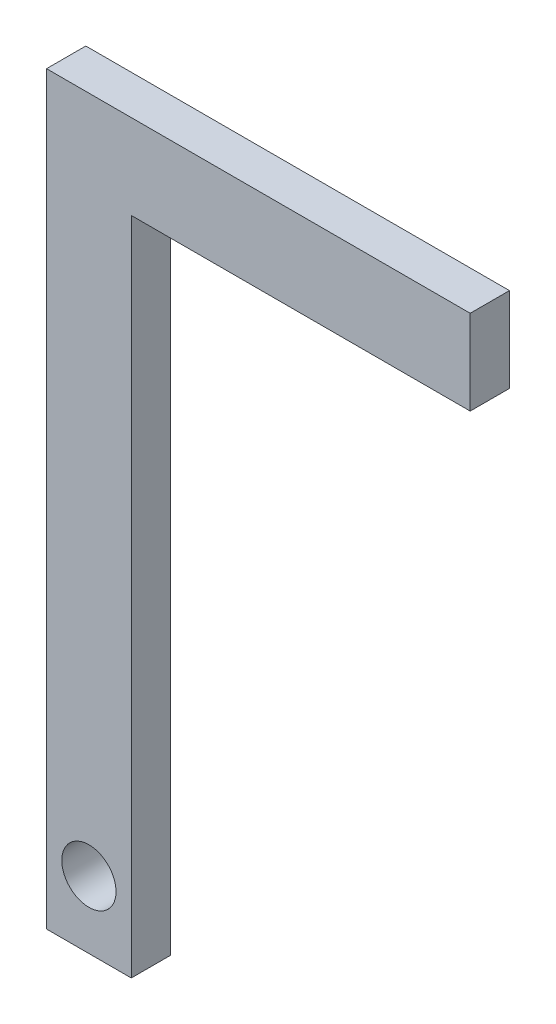
from build123d import *

# Parameters (mm, degrees)
SKETCH_3_W          = 15
SKETCH_3_H          = 131.91272758
EXTRUDE_2_DEPTH     = 6.95
SKETCH_4_W          = 60
SKETCH_4_H          = 15
EXTRUDE_3_DEPTH     = 6.95
SKETCH_5_R          = 4.8
CUT_EXTRUDE_5_DEPTH = 7.95


with BuildPart() as part:
    # 草图3 → 凸台-拉伸2 (new body)
    with BuildSketch(Plane.XY):
        with Locations((-3.781807483, 0)):
            Rectangle(SKETCH_3_W, SKETCH_3_H)
    extrude(amount=EXTRUDE_2_DEPTH)

    # 草图4 → 凸台-拉伸3 (add)
    with BuildSketch(Plane.XY):
        with Locations((33.718192517, 58.45636379)):
            Rectangle(SKETCH_4_W, SKETCH_4_H)
    extrude(amount=EXTRUDE_3_DEPTH)

    # 草图5 → 切除-拉伸5 (cut, through all)
    with BuildSketch(Plane.XY):
        with Locations((-3.781807483, -54.073012812)):
            Circle(SKETCH_5_R)
    extrude(amount=CUT_EXTRUDE_5_DEPTH, mode=Mode.SUBTRACT)


solid = part.part
